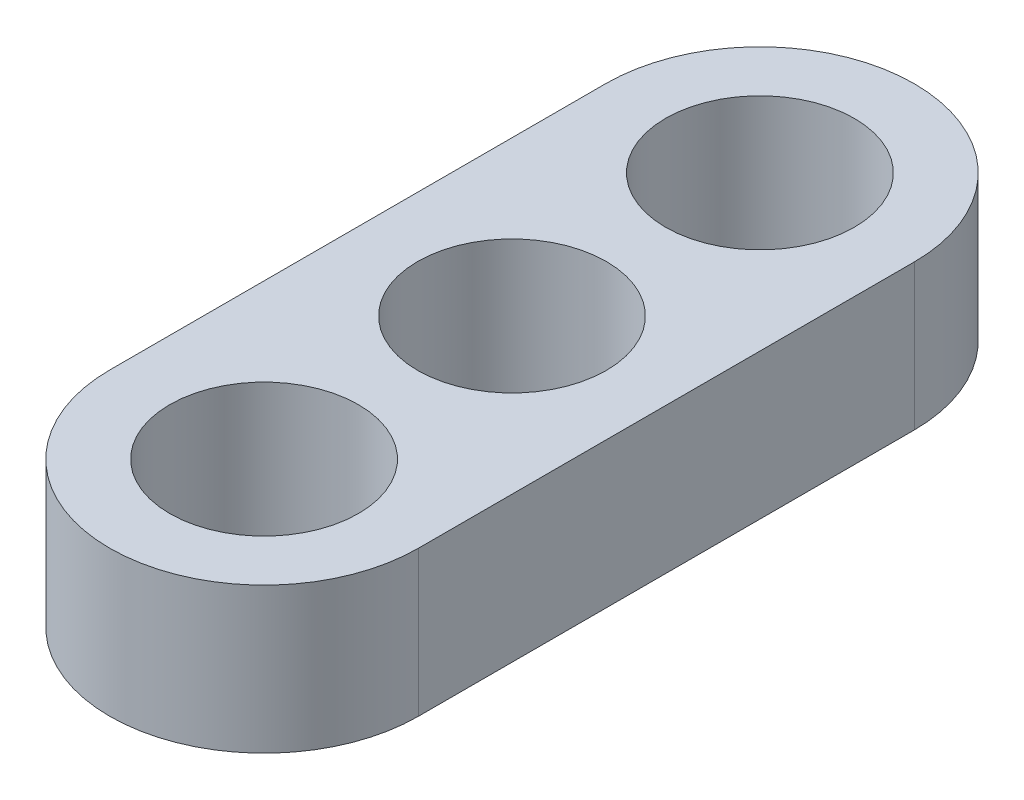
from build123d import *

# Parameters (mm, degrees)
SKETCH1_R           = 1.4986
BOSS_EXTRUDE1_DEPTH = 2.3114


with BuildPart() as part:
    # Sketch1 → Boss-Extrude1 (new body)
    with BuildSketch(Plane(origin=(0, 0, 0), x_dir=(1, 0, 0), z_dir=(0, 1, 0))):
        with BuildLine():
            Line((-2.4511, -3.937), (-2.4511, 3.937))
            ThreePointArc((-2.4511, 3.937), (0, 6.3881), (2.4511, 3.937))
            Line((2.4511, 3.937), (2.4511, -3.937))
            ThreePointArc((2.4511, -3.937), (0, -6.3881), (-2.4511, -3.937))
        make_face()
        with Locations((0, 3.937)):
            Circle(SKETCH1_R, mode=Mode.SUBTRACT)
        with Locations((0, -3.937)):
            Circle(SKETCH1_R, mode=Mode.SUBTRACT)
        Circle(SKETCH1_R, mode=Mode.SUBTRACT)
    extrude(amount=BOSS_EXTRUDE1_DEPTH)


solid = part.part
